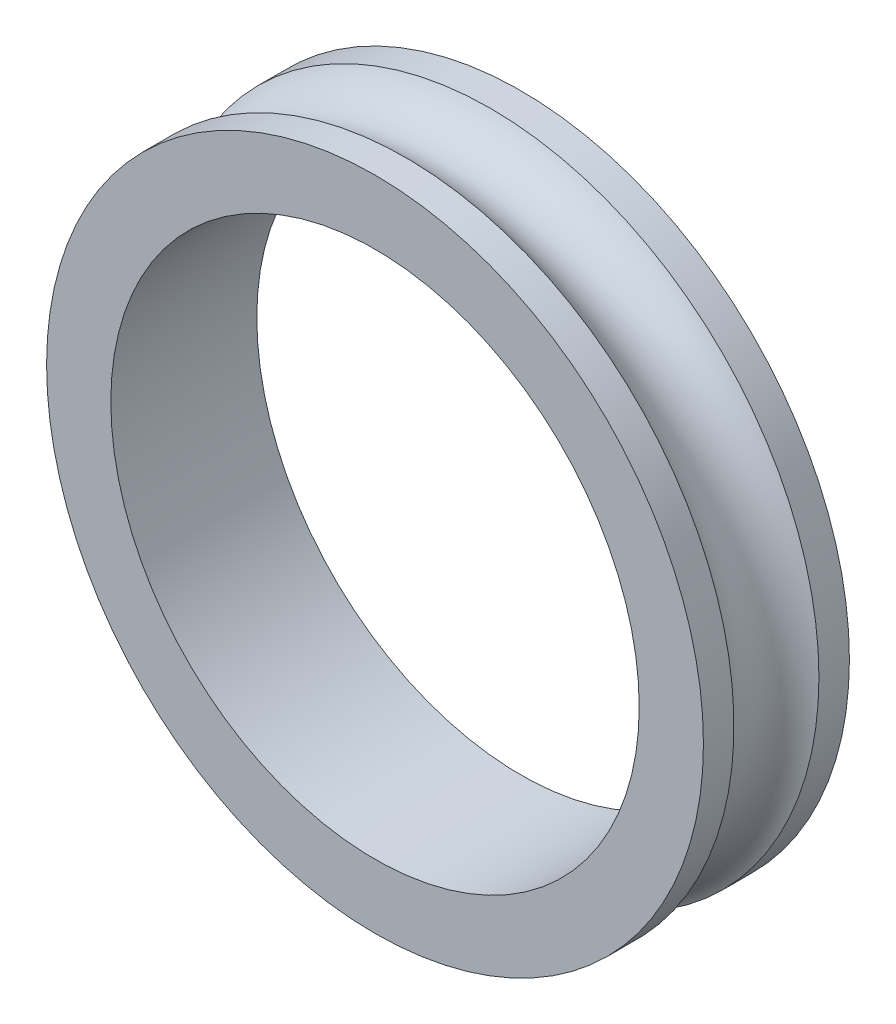
from build123d import *

# Parameters (mm, degrees)
SKETCH1_R           = 22.5
BOSS_EXTRUDE1_DEPTH = 10
CUT_EXTRUDE1_REACH  = 12
SKETCH2_R           = 18.1
SKETCH3_R           = 3.275


with BuildPart() as part:
    # Sketch1 → Boss-Extrude1 (new body)
    with BuildSketch(Plane.XY):
        Circle(SKETCH1_R)
    extrude(amount=BOSS_EXTRUDE1_DEPTH)

    # Sketch2 → Cut-Extrude1 (cut, up to next)
    with BuildSketch(Plane.XY.offset(10), mode=Mode.PRIVATE) as cut_extrude1_sk1:
        Circle(SKETCH2_R)
    cut_extrude1_tool1 = extrude(cut_extrude1_sk1.sketch, amount=-CUT_EXTRUDE1_REACH, mode=Mode.PRIVATE) & part.part
    add(cut_extrude1_tool1.solids().sort_by_distance((0, 0, 10))[0], mode=Mode.SUBTRACT)

    # Sketch3 → Cut-Revolve1 (revolve, cut)
    with BuildSketch(Plane(origin=(0, 0, 0), x_dir=(1, 0, 0), z_dir=(0, 1, 0))):
        with Locations((-24, -5)):
            Circle(SKETCH3_R)
    revolve(axis=Axis((0, 0, -18.462767292), (0, 0, 1)), mode=Mode.SUBTRACT)


solid = part.part
